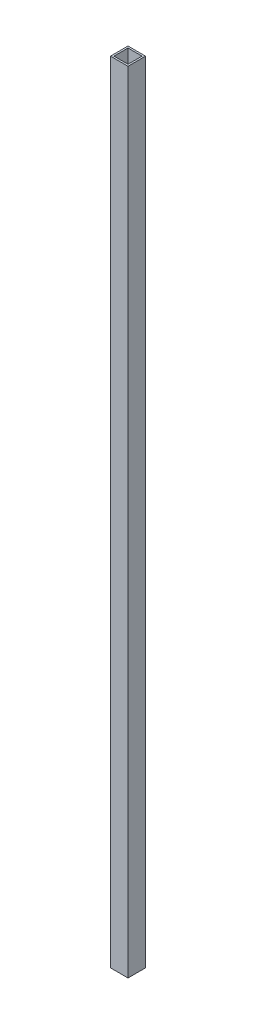
from build123d import *

# Parameters (mm, degrees)
SKETCH1_W           = 20
SKETCH1_H           = 900
BOSS_EXTRUDE1_DEPTH = 20
SKETCH2_W           = 16
SKETCH2_H           = 16
CUT_EXTRUDE1_DEPTH  = 200


with BuildPart() as part:
    # Sketch1 → Boss-Extrude1 (new body)
    with BuildSketch(Plane.XY):
        with Locations((-21.739130435, -400.217391304)):
            Rectangle(SKETCH1_W, SKETCH1_H)
    extrude(amount=-BOSS_EXTRUDE1_DEPTH)

    # Sketch2 → Cut-Extrude1 (cut)
    with BuildSketch(Plane(origin=(0, 49.782608696, 0), x_dir=(1, 0, 0), z_dir=(0, 1, 0))):
        with Locations((-21.739130435, 10)):
            Rectangle(SKETCH2_W, SKETCH2_H)
    extrude(amount=-CUT_EXTRUDE1_DEPTH, mode=Mode.SUBTRACT)


solid = part.part
